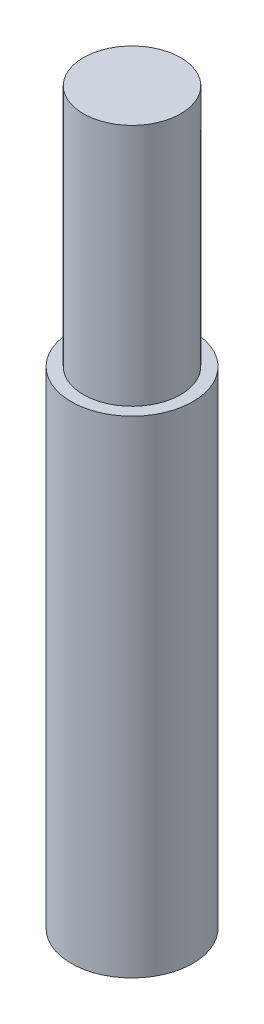
from build123d import *

# Parameters (mm, degrees)
IZIM2_R               = 2
KES_EKSTR_ZYON1_DEPTH = 10
RADYUS1_R             = 0.4


with BuildPart() as part:
    # Çizim1 → Döndür1 (revolve)
    with BuildSketch(Plane.XY):
        Polygon((0, 0), (0, 30), (2, 30), (2, 20), (2.5, 20), (2.5, 0), align=None)
    revolve(axis=Axis((0, 0, 0), (0, 1, 0)))

    # Çizim2 → Kes-Ekstrüzyon1 (cut)
    with BuildSketch(Plane.XZ):
        Circle(IZIM2_R)
    extrude(amount=-KES_EKSTR_ZYON1_DEPTH, mode=Mode.SUBTRACT)

    # Radyus1
    radyus1_edges = [part.edges().sort_by_distance(p)[0] for p in [
        (-2, 0, 0),
    ]]
    fillet(radyus1_edges, radius=RADYUS1_R)


solid = part.part
